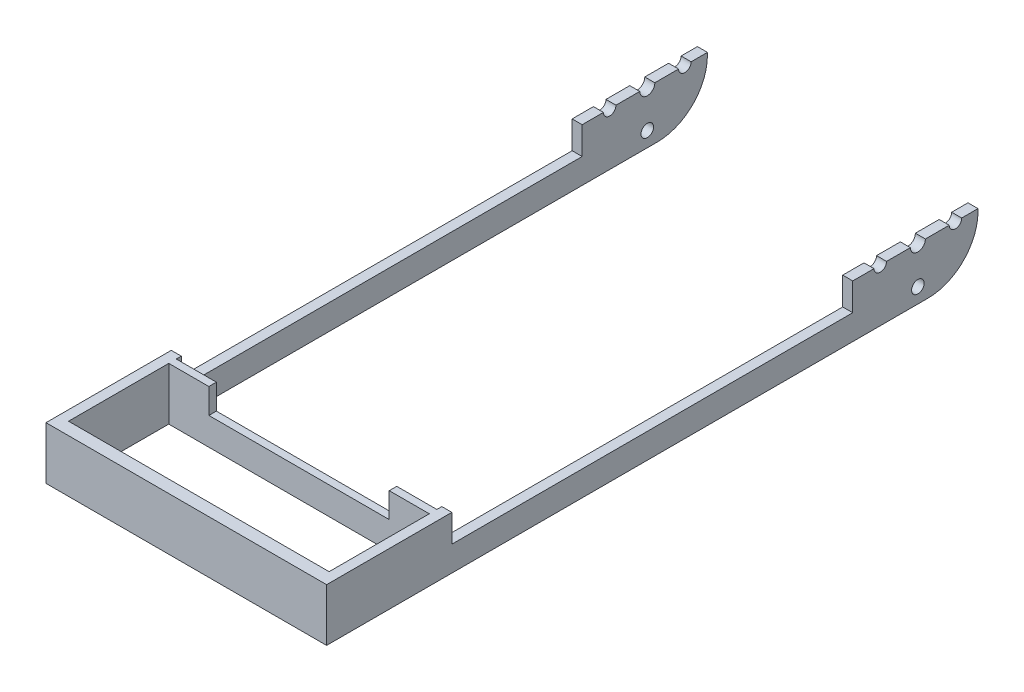
from build123d import *

# Parameters (mm, degrees)
SKETCH3_W           = 56
SKETCH3_H           = 21
BOSS_EXTRUDE1_DEPTH = 130
SKETCH4_W           = 52
SKETCH4_H           = 106
SKETCH4_H_2         = 20
CUT_EXTRUDE3_DEPTH  = 22
SKETCH6_R           = 1.5
SKETCH6_R_2         = 1.25
CUT_EXTRUDE4_DEPTH  = 57
FILLET1_R           = 10
SKETCH7_W           = 80
SKETCH7_H           = 10
CUT_EXTRUDE5_DEPTH  = 57
SKETCH8_W           = 36
SKETCH8_H           = 10
CUT_EXTRUDE6_DEPTH  = 2
CUT_EXTRUDE7_DEPTH  = 57


with BuildPart() as part:
    # Sketch3 → Boss-Extrude1 (new body)
    with BuildSketch(Plane.XY):
        Rectangle(SKETCH3_W, SKETCH3_H)
    extrude(amount=BOSS_EXTRUDE1_DEPTH)

    # Sketch4 → Cut-Extrude3 (cut, through all)
    with BuildSketch(Plane.XZ.offset(10.5)):
        with Locations((0, 53)):
            Rectangle(SKETCH4_W, SKETCH4_H)
        with Locations((0, 117.5)):
            Rectangle(SKETCH4_W, SKETCH4_H_2)
    extrude(amount=-CUT_EXTRUDE3_DEPTH, mode=Mode.SUBTRACT)

    # Sketch6 → Cut-Extrude4 (cut, through all)
    with BuildSketch(Plane(origin=(28, 0, 0), x_dir=(0, 0, -1), z_dir=(1, 0, 0))):
        with Locations((-12, 0)):
            Circle(SKETCH6_R)
        with Locations((-4.5, 0)):
            Circle(SKETCH6_R_2)
        with Locations((-19.5, 0)):
            Circle(SKETCH6_R_2)
        with Locations((-12, 7.5)):
            Circle(SKETCH6_R_2)
        with Locations((-12, -7.5)):
            Circle(SKETCH6_R_2)
    extrude(amount=-CUT_EXTRUDE4_DEPTH, mode=Mode.SUBTRACT)

    # Fillet1
    fillet1_edges = [part.edges().sort_by_distance(p)[0] for p in [
        (27, -10.5, 0),
        (-27, 10.5, 0),
        (-27, -10.5, 0),
        (27, 10.5, 0),
    ]]
    fillet(fillet1_edges, radius=FILLET1_R)

    # Sketch7 → Cut-Extrude5 (cut, through all)
    with BuildSketch(Plane(origin=(28, 0, 0), x_dir=(0, 0, -1), z_dir=(1, 0, 0))):
        with Locations((-65, -0.5)):
            Rectangle(SKETCH7_W, SKETCH7_H)
    extrude(amount=-CUT_EXTRUDE5_DEPTH, mode=Mode.SUBTRACT)

    # Sketch8 → Cut-Extrude6 (cut)
    with BuildSketch(Plane(origin=(0, 0, 106), x_dir=(-1, 0, 0), z_dir=(0, 0, -1))):
        Rectangle(SKETCH8_W, SKETCH8_H)
    extrude(amount=-CUT_EXTRUDE6_DEPTH, mode=Mode.SUBTRACT)

    # Sketch9 → Cut-Extrude7 (cut, through all)
    with BuildSketch(Plane(origin=(28, 0, 0), x_dir=(0, 0, -1), z_dir=(1, 0, 0))):
        Polygon((8.328518313, 0), (-140.648225394, 0), (-140.648225394, 18.171038809), (9.8749897, 18.171038809), (9.8749897, 0), align=None)
    extrude(amount=-CUT_EXTRUDE7_DEPTH, mode=Mode.SUBTRACT)


solid = part.part
